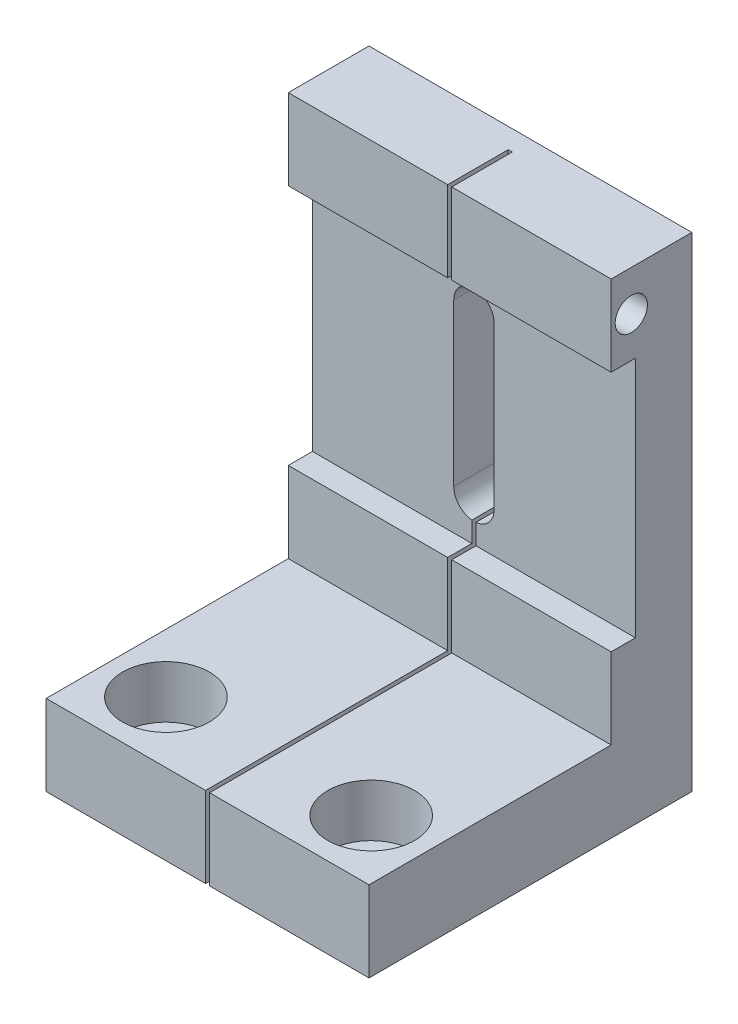
from build123d import *

# Parameters (mm, degrees)
SKETCH1_W           = 40
SKETCH1_H           = 60
BOSS_EXTRUDE1_DEPTH = 10
CUT_EXTRUDE1_DEPTH  = 11
SKETCH5_W           = 3
SKETCH5_H           = 30
CUT_EXTRUDE4_DEPTH  = 41
SKETCH6_W           = 40
SKETCH6_H           = 10
BOSS_EXTRUDE2_DEPTH = 30
SKETCH8_W           = 0.5
SKETCH8_H           = 37.5
CUT_EXTRUDE7_DEPTH  = 60
SKETCH10_R          = 2
CUT_EXTRUDE10_DEPTH = 30
SKETCH12_R          = 3.4
SKETCH12_R_2        = 2.49
CUT_EXTRUDE13_DEPTH = 10
SKETCH14_R          = 5.375
CUT_EXTRUDE14_DEPTH = 6.5


with BuildPart() as part:
    # Sketch1 → Boss-Extrude1 (new body)
    with BuildSketch(Plane.XY):
        with Locations((-20, -30)):
            Rectangle(SKETCH1_W, SKETCH1_H)
    extrude(amount=BOSS_EXTRUDE1_DEPTH)

    # Sketch2 → Cut-Extrude1 (cut, through all)
    with BuildSketch(Plane.XY.offset(10)):
        with BuildLine():
            Line((-17.5, -15), (-17.5, -35))
            ThreePointArc((-17.5, -35), (-20, -37.5), (-22.5, -35))
            Line((-22.5, -35), (-22.5, -15))
            ThreePointArc((-22.5, -15), (-20, -12.5), (-17.5, -15))
        make_face()
    extrude(amount=-CUT_EXTRUDE1_DEPTH, mode=Mode.SUBTRACT)

    # Sketch5 → Cut-Extrude4 (cut, through all)
    with BuildSketch(Plane(origin=(0, 0, 0), x_dir=(0, 0, -1), z_dir=(1, 0, 0))):
        with Locations((-8.5, -25)):
            Rectangle(SKETCH5_W, SKETCH5_H)
    extrude(amount=-CUT_EXTRUDE4_DEPTH, mode=Mode.SUBTRACT)

    # Sketch6 → Boss-Extrude2 (add)
    with BuildSketch(Plane.XY.offset(10)):
        with Locations((-20, -55)):
            Rectangle(SKETCH6_W, SKETCH6_H)
    extrude(amount=BOSS_EXTRUDE2_DEPTH)

    # Sketch8 → Cut-Extrude7 (cut)
    with BuildSketch(Plane(origin=(0, 0, 0), x_dir=(1, 0, 0), z_dir=(0, 1, 0))):
        with Locations((-20, -21.25)):
            Rectangle(SKETCH8_W, SKETCH8_H)
    extrude(amount=-CUT_EXTRUDE7_DEPTH, mode=Mode.SUBTRACT)

    # Sketch10 → Cut-Extrude10 (cut)
    with BuildSketch(Plane(origin=(0, 0, 0), x_dir=(0, 0, -1), z_dir=(1, 0, 0))):
        with Locations((-7.5, -5)):
            Circle(SKETCH10_R)
    extrude(amount=-CUT_EXTRUDE10_DEPTH, mode=Mode.SUBTRACT)

    # Sketch12 → Cut-Extrude13 (cut)
    with BuildSketch(Plane.XZ.offset(60)):
        with Locations((-7.3, 32.43)):
            Circle(SKETCH12_R)
        with Locations((-32.73, 32.43)):
            Circle(SKETCH12_R)
        with Locations((-32.73, 7)):
            Circle(SKETCH12_R_2)
        with Locations((-7.3, 7)):
            Circle(SKETCH12_R_2)
    extrude(amount=-CUT_EXTRUDE13_DEPTH, mode=Mode.SUBTRACT)

    # Sketch14 → Cut-Extrude14 (cut)
    with BuildSketch(Plane(origin=(0, -50, 0), x_dir=(1, 0, 0), z_dir=(0, 1, 0))):
        with Locations((-32.73, -32.43)):
            Circle(SKETCH14_R)
        with Locations((-7.3, -32.43)):
            Circle(SKETCH14_R)
    extrude(amount=-CUT_EXTRUDE14_DEPTH, mode=Mode.SUBTRACT)


solid = part.part
